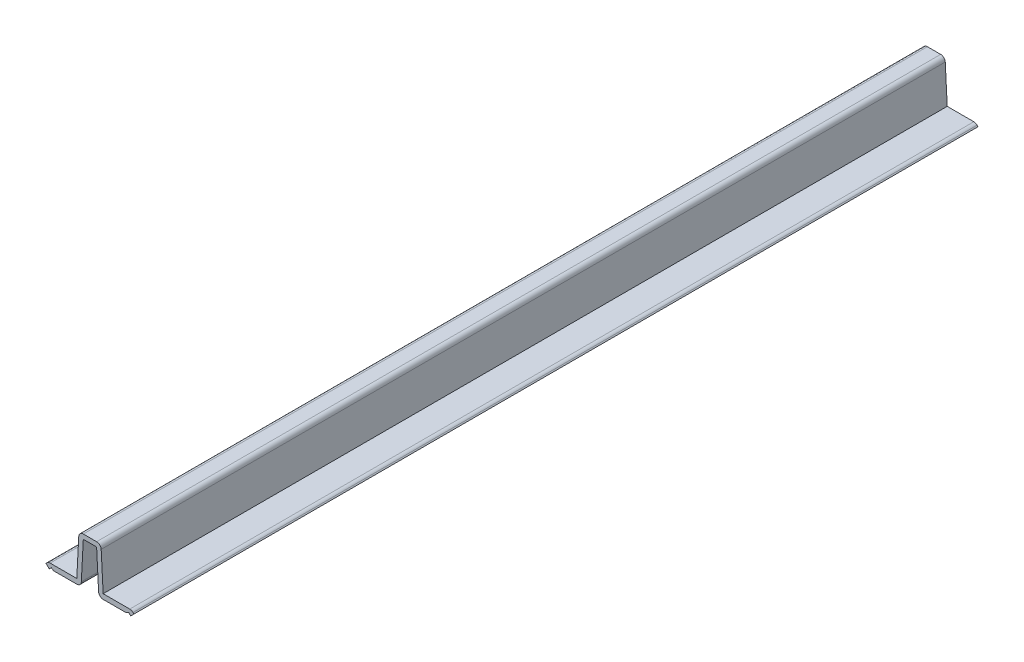
from build123d import *

# Parameters (mm, degrees)
BOSS_EXTRUDE1_DEPTH = 304.8
FILLET1_R           = 1.651


with BuildPart() as part:
    # Sketch1 → Boss-Extrude1 (new body)
    with BuildSketch(Plane.XY):
        Polygon((-4.7625, 1.984375), (-15.060088734, 1.984375), (-15.875, 1.162346283), (-14.702501762, 0), (-13.954431554, 0.754603868), (-13.121373906, 0.197134811), (-3.203280151, 0.197134811), (-2.402359615, 15.414625), (0, 15.414625), (2.402359615, 15.414625), (3.203280151, 0.197134811), (13.121373906, 0.197134811), (13.954431554, 0.754603868), (14.702501762, 0), (15.875, 1.162346283), (15.060088734, 1.984375), (4.7625, 1.984375), (3.96875, 17.065625), (0, 17.065625), (-3.96875, 17.065625), align=None)
    extrude(amount=-BOSS_EXTRUDE1_DEPTH)

    # Fillet1
    fillet1_edges = [part.edges().sort_by_distance(p)[0] for p in [
        (-15.060088734, 1.984375, -152.4),
        (-3.96875, 17.065625, -152.4),
        (3.96875, 17.065625, -152.4),
        (15.060088734, 1.984375, -152.4),
        (3.203280151, 0.197134811, -152.4),
        (-3.203280151, 0.197134811, -152.4),
    ]]
    fillet(fillet1_edges, radius=FILLET1_R)


solid = part.part
